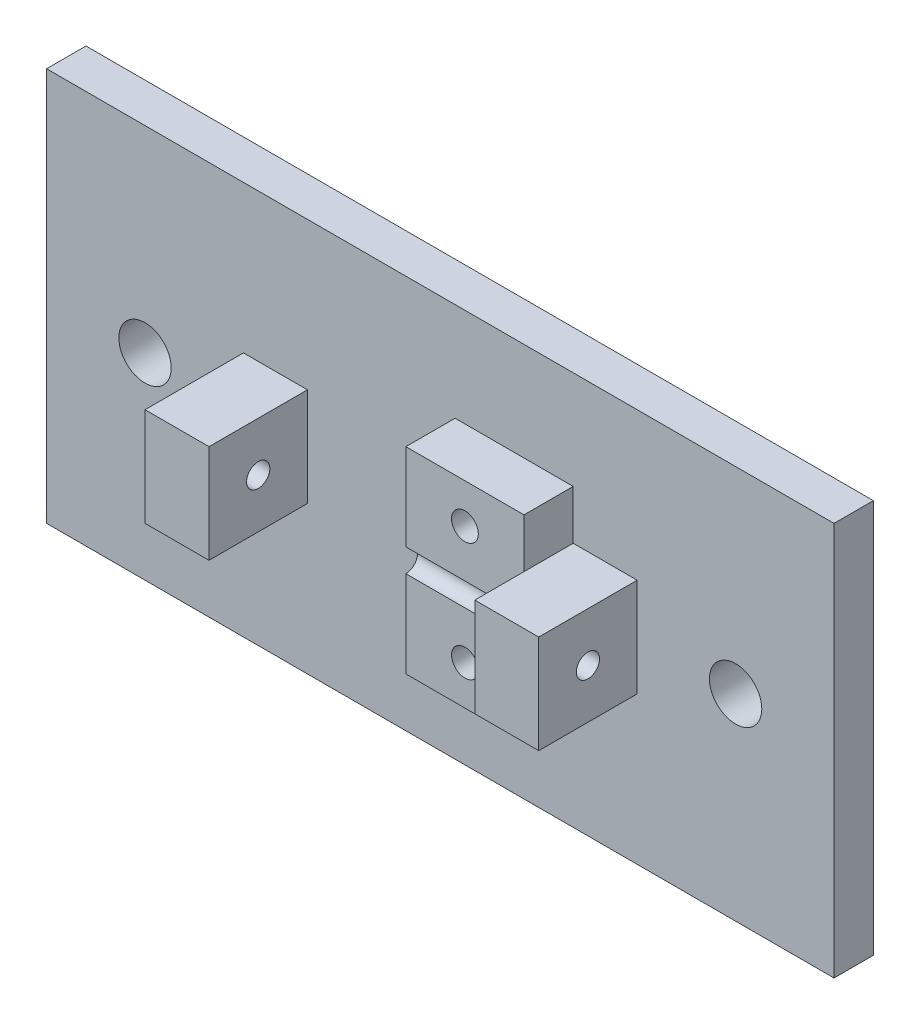
from build123d import *
from build123d.topology import SkipClean

# Parameters (mm, degrees)
SKETCH1_W                   = 101.6
SKETCH1_H                   = 50.8
BOSS_EXTRUDE1_DEPTH         = 5.08
H_0_266_DIAMETER_HOLE1_D    = 6.7564
SKETCH5_W                   = 8.255
SKETCH5_H                   = 12.7
BOSS_EXTRUDE2_DEPTH         = 12.7
SKETCH6_R                   = 1.5
CUT_EXTRUDE1_DEPTH          = 12.7
BOSS_EXTRUDE3_DEPTH         = 15.24
SKETCH9_W                   = 15.24
SKETCH9_H                   = 6.35
BOSS_EXTRUDE4_DEPTH         = 6.35
F_29_0_136_DIAMETER_HOLE1_D = 3.4544


with BuildPart() as part:
    # Sketch1 → Boss-Extrude1 (new body)
    with BuildSketch(Plane.XY):
        Rectangle(SKETCH1_W, SKETCH1_H)
    extrude(amount=BOSS_EXTRUDE1_DEPTH)

    # H _0.266_ Diameter Hole1 (through all)
    with Locations(Plane.XY.offset(5.08)):
        with Locations((38.1, 0), (-38.1, 0)):
            Hole(H_0_266_DIAMETER_HOLE1_D / 2)

    # Sketch5 → Boss-Extrude2 (add)
    with BuildSketch(Plane.XY.offset(5.08)):
        with Locations((-21.2725, 0)):
            Rectangle(SKETCH5_W, SKETCH5_H)
    boss_extrude2 = extrude(amount=BOSS_EXTRUDE2_DEPTH)

    # Sketch6 → Cut-Extrude1 (cut)
    with BuildSketch(Plane.ZY.offset(25.4)):
        with Locations((11.43, 0)):
            Circle(SKETCH6_R)
    cut_extrude1 = extrude(amount=-CUT_EXTRUDE1_DEPTH, mode=Mode.SUBTRACT)

    # Mirror1: Boss-Extrude2, Cut-Extrude1 across plane
    add(boss_extrude2.mirror(Plane(origin=(0, 0, 0), x_dir=(0, 0, 1), z_dir=(1, 0, 0))))
    add(cut_extrude1.mirror(Plane(origin=(0, 0, 0), x_dir=(0, 0, 1), z_dir=(1, 0, 0))), mode=Mode.SUBTRACT)

    # Sketch8 → Boss-Extrude3 (add)
    with SkipClean():  # the faces are left unmerged after this step: merging them gives an invalid solid
        with BuildSketch(Plane.ZY.offset(-17.145)):
            with BuildLine():
                Line((11.43, 6.35), (5.08, 6.35))
                Line((5.08, 6.35), (5.08, -6.35))
                Line((5.08, -6.35), (11.43, -6.35))
                Line((11.43, -6.35), (11.43, -1.5))
                ThreePointArc((11.43, -1.5), (9.93, 0), (11.43, 1.5))
                Line((11.43, 1.5), (11.43, 6.35))
            make_face()
        extrude(amount=BOSS_EXTRUDE3_DEPTH)

    # Sketch9 → Boss-Extrude4 (add)
    with SkipClean():  # the faces are left unmerged after this step: merging them gives an invalid solid
        with BuildSketch(Plane(origin=(0, 6.35, 0), x_dir=(1, 0, 0), z_dir=(0, 1, 0))):
            with Locations((9.525, -8.255)):
                Rectangle(SKETCH9_W, SKETCH9_H)
        boss_extrude4 = extrude(amount=BOSS_EXTRUDE4_DEPTH)

    # Mirror2: Boss-Extrude4 across plane
    with SkipClean():  # the faces are left unmerged after this step: merging them gives an invalid solid
        add(boss_extrude4.mirror(Plane.ZX))

    # 29 _0.136_ Diameter Hole1 (through all)
    with Locations(Plane.XY.offset(11.43)):
        with Locations((9.525, -7.62), (9.525, 7.62)):
            Hole(F_29_0_136_DIAMETER_HOLE1_D / 2)


solid = part.part
